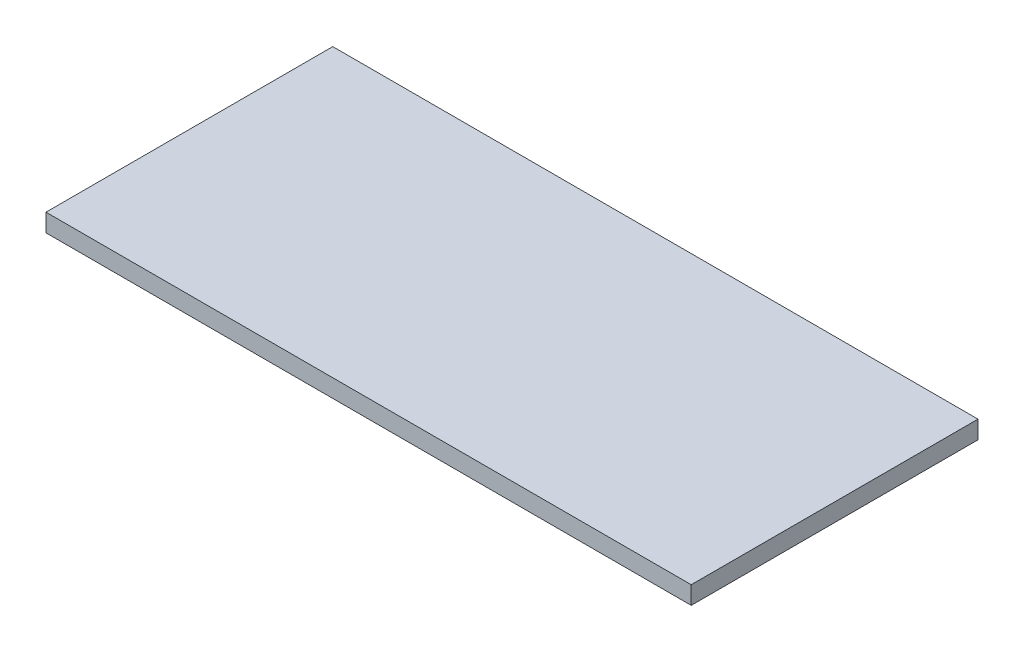
from build123d import *

# Parameters (mm, degrees)
SKETCH1_W           = 720
SKETCH1_H           = 320
BOSS_EXTRUDE1_DEPTH = 10


with BuildPart() as part:
    # Sketch1 → Boss-Extrude1 (new body, symmetric)
    with BuildSketch(Plane(origin=(0, 0, 0), x_dir=(1, 0, 0), z_dir=(0, 1, 0))):
        Rectangle(SKETCH1_W, SKETCH1_H)
    extrude(amount=BOSS_EXTRUDE1_DEPTH, both=True)


solid = part.part
